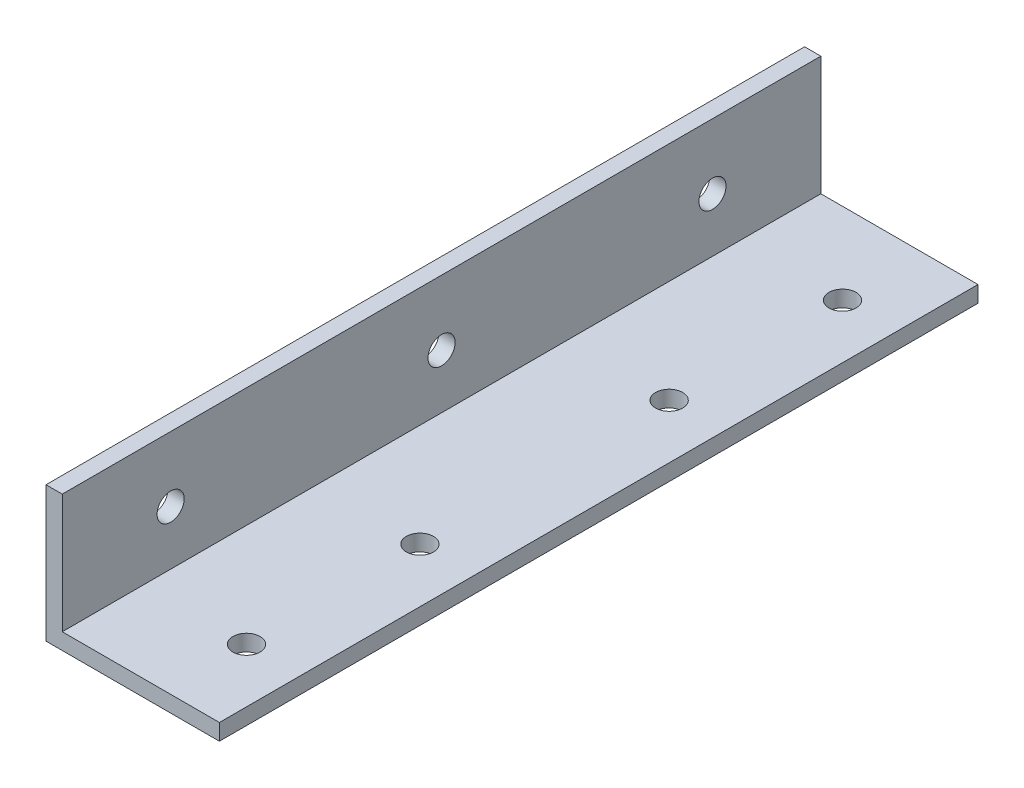
from build123d import *

# Parameters (mm, degrees)
BOSS_EXTRUDE2_DEPTH            = 140
HOLE_FOR_M5_300_SC_NUTS_SP_1_D = 5
HOLE_FOR_M5_300_SC_NUTS_SP_2_D = 5


with BuildPart() as part:
    # Sketch2 → Boss-Extrude2 (new body)
    with BuildSketch(Plane.XY):
        Polygon((-10.037935248, 20.448337429), (-10.037935248, -1.551662571), (18.962064752, -1.551662571), (18.962064752, -4.551662571), (-13.037935248, -4.551662571), (-13.037935248, 20.448337429), align=None)
    extrude(amount=BOSS_EXTRUDE2_DEPTH)

    # Hole for M5 300® SC Nuts (SP)1 (through all)
    with Locations(Plane(origin=(8.962064752, -1.551662571, 15), x_dir=(0, 0, 1), z_dir=(0, 1, 0))):
        with Locations((0, 0), (32, 0), (78, 0), (110, 0)):
            Hole(HOLE_FOR_M5_300_SC_NUTS_SP_1_D / 2)

    # Hole for M5 300® SC Nuts (SP)2 (through all)
    with Locations(Plane(origin=(-10.037935248, 0, 0), x_dir=(0, 0, -1), z_dir=(1, 0, 0))):
        with Locations((-20, 8.448337429), (-70, 8.448337429), (-120, 8.448337429)):
            Hole(HOLE_FOR_M5_300_SC_NUTS_SP_2_D / 2)


solid = part.part
